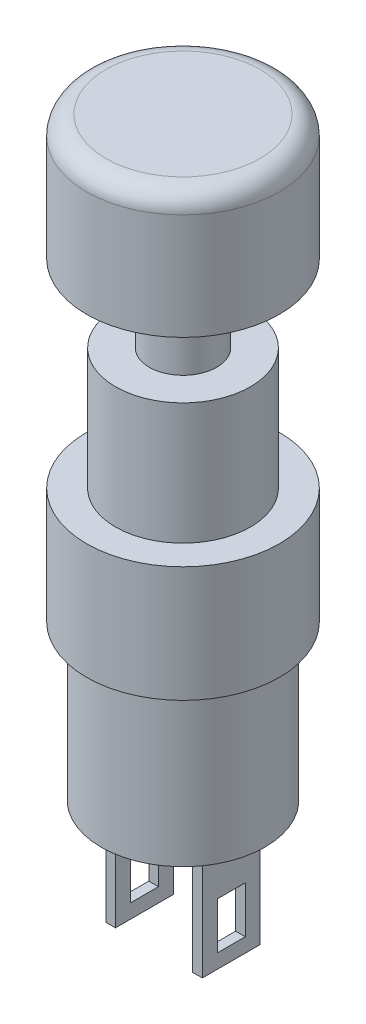
from build123d import *

# Parameters (mm, degrees)
ESBO_O1_R                = 5
RESSALTO_EXTRUS_O1_DEPTH = 6
ESBO_O2_R                = 4.25
RESSALTO_EXTRUS_O2_DEPTH = 8
ESBO_O3_W                = 0.5
ESBO_O3_H                = 3
RESSALTO_EXTRUS_O3_DEPTH = 6
ESBO_O4_W                = 1.442967266
ESBO_O4_H                = 2.423445024
CORTE_EXTRUS_O1_DEPTH    = 8.5
ESBO_O5_R                = 3.5
RESSALTO_EXTRUS_O4_DEPTH = 6.3
ESBO_O6_R                = 1.75
RESSALTO_EXTRUS_O5_DEPTH = 4
ESBO_O7_R                = 5
RESSALTO_EXTRUS_O6_DEPTH = 6.5
FILETE1_R                = 1


with BuildPart() as part:
    # Esboço1 → Ressalto-extrusão1 (new body)
    with BuildSketch(Plane(origin=(0, 0, 0), x_dir=(1, 0, 0), z_dir=(0, 1, 0))):
        Circle(ESBO_O1_R)
    extrude(amount=RESSALTO_EXTRUS_O1_DEPTH)

    # Esboço2 → Ressalto-extrusão2 (add)
    with BuildSketch(Plane.XZ):
        Circle(ESBO_O2_R)
    extrude(amount=RESSALTO_EXTRUS_O2_DEPTH)

    # Esboço3 → Ressalto-extrusão3 (add)
    with BuildSketch(Plane.XZ.offset(8)):
        with Locations((2.25, 0)):
            Rectangle(ESBO_O3_W, ESBO_O3_H)
        with Locations((-2.25, 0)):
            Rectangle(ESBO_O3_W, ESBO_O3_H)
    extrude(amount=RESSALTO_EXTRUS_O3_DEPTH)

    # Esboço4 → Corte-extrusão1 (cut, through all)
    with BuildSketch(Plane.ZY.offset(2.5)):
        with Locations((-0.007097641, -12.050464305)):
            Rectangle(ESBO_O4_W, ESBO_O4_H)
    extrude(amount=-CORTE_EXTRUS_O1_DEPTH, mode=Mode.SUBTRACT)

    # Esboço5 → Ressalto-extrusão4 (add)
    with BuildSketch(Plane(origin=(0, 6, 0), x_dir=(1, 0, 0), z_dir=(0, 1, 0))):
        Circle(ESBO_O5_R)
    extrude(amount=RESSALTO_EXTRUS_O4_DEPTH)

    # Esboço6 → Ressalto-extrusão5 (add)
    with BuildSketch(Plane(origin=(0, 12.3, 0), x_dir=(1, 0, 0), z_dir=(0, 1, 0))):
        Circle(ESBO_O6_R)
    extrude(amount=RESSALTO_EXTRUS_O5_DEPTH)

    # Esboço7 → Ressalto-extrusão6 (add)
    with BuildSketch(Plane(origin=(0, 16.3, 0), x_dir=(1, 0, 0), z_dir=(0, 1, 0))):
        Circle(ESBO_O7_R)
    extrude(amount=RESSALTO_EXTRUS_O6_DEPTH)

    # Filete1
    filete1_edges = [part.edges().sort_by_distance(p)[0] for p in [
        (-5, 22.8, 0),
    ]]
    fillet(filete1_edges, radius=FILETE1_R)


solid = part.part
